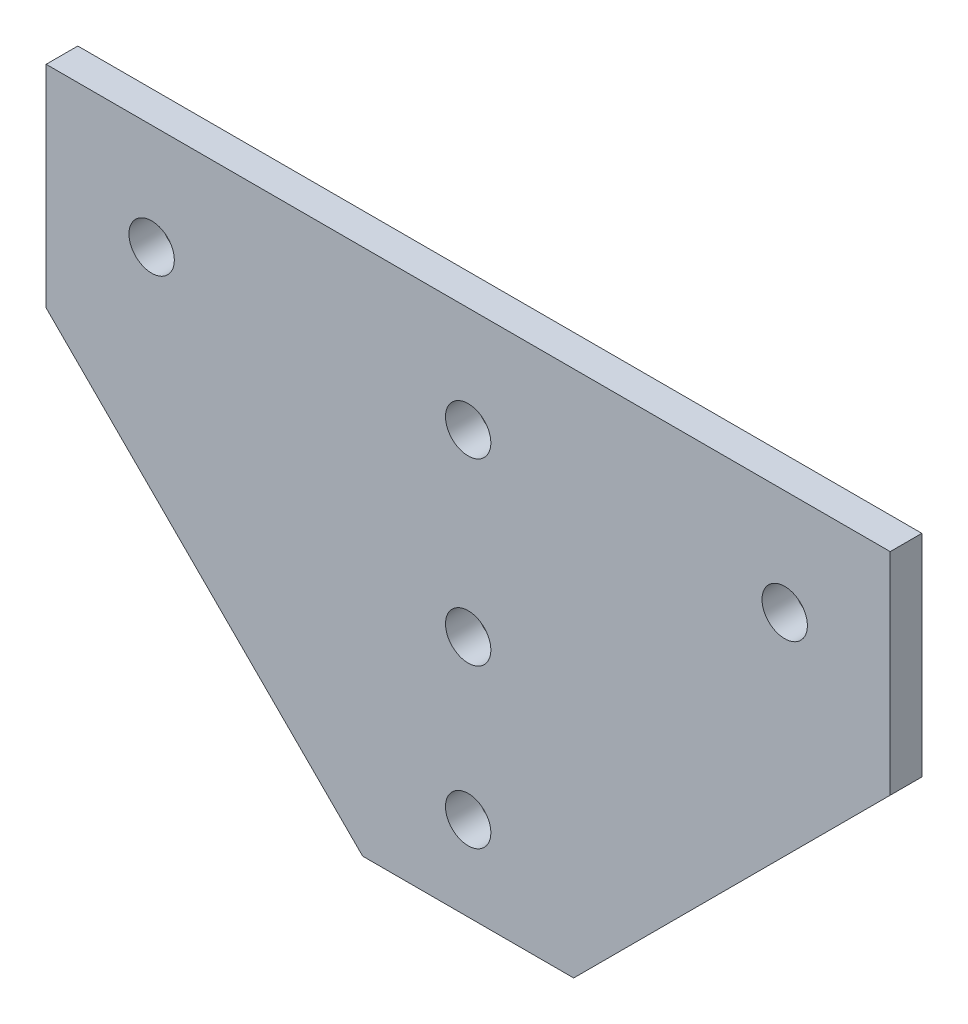
from build123d import *

# Parameters (mm, degrees)
SKETCH1_R           = 2.15
BOSS_EXTRUDE1_DEPTH = 3


with BuildPart() as part:
    # Sketch1 → Boss-Extrude1 (new body)
    with BuildSketch(Plane.XY):
        Polygon((-412.094950635, 20), (-412.094950635, 0), (-382.094950635, -30), (-362.094950635, -30), (-332.094950635, 0), (-332.094950635, 20), align=None)
        with Locations((-402.094950635, 10)):
            Circle(SKETCH1_R, mode=Mode.SUBTRACT)
        with Locations((-342.094950635, 10)):
            Circle(SKETCH1_R, mode=Mode.SUBTRACT)
        with Locations((-372.094950635, -22)):
            Circle(SKETCH1_R, mode=Mode.SUBTRACT)
        with Locations((-372.094950635, -7)):
            Circle(SKETCH1_R, mode=Mode.SUBTRACT)
        with Locations((-372.094950635, 10)):
            Circle(SKETCH1_R, mode=Mode.SUBTRACT)
    extrude(amount=BOSS_EXTRUDE1_DEPTH)


solid = part.part
